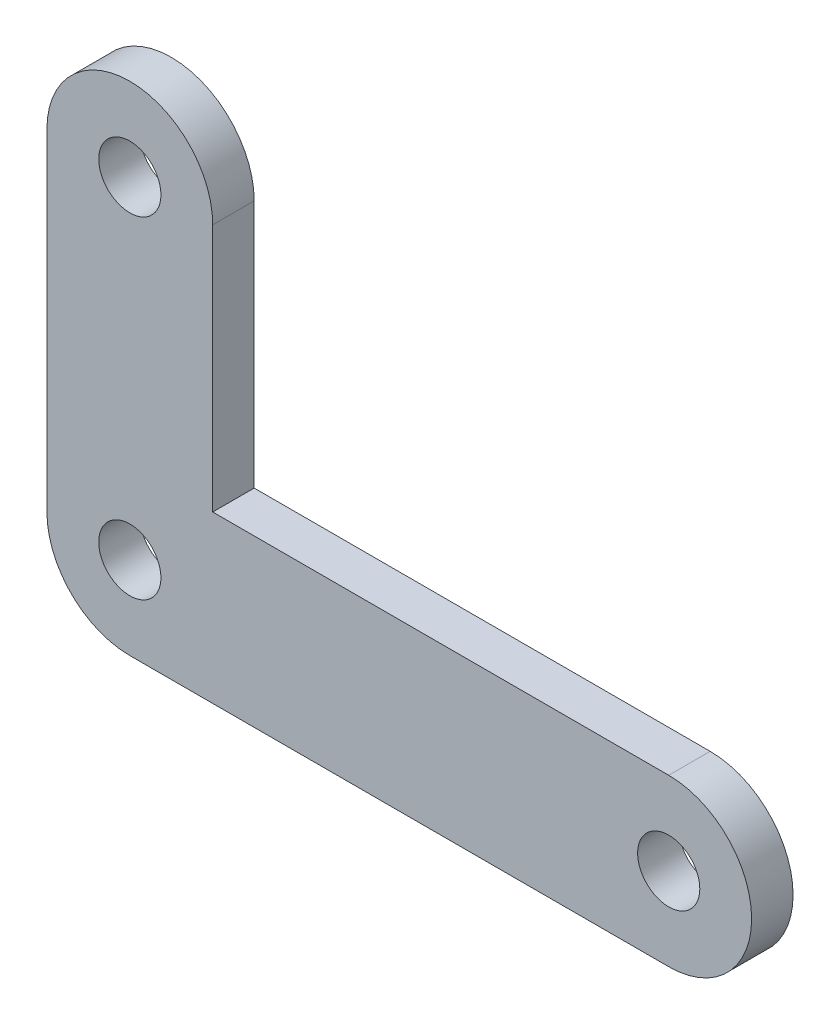
from build123d import *

# Parameters (mm, degrees)
SKETCH1_R           = 4.7625
BOSS_EXTRUDE1_DEPTH = 6.35


with BuildPart() as part:
    # Sketch1 → Boss-Extrude1 (new body)
    with BuildSketch(Plane.XY):
        with BuildLine():
            Line((-95.25, 50.8), (-95.25, 0))
            ThreePointArc((-95.25, 0), (-91.530256121, 8.980256121), (-82.55, 12.7))
            Line((-82.55, 12.7), (-69.85, 12.7))
            Line((-69.85, 12.7), (-69.85, 50.8))
            ThreePointArc((-69.85, 50.8), (-82.55, 63.5), (-95.25, 50.8))
        make_face()
        with Locations((-82.55, 50.8)):
            Circle(SKETCH1_R, mode=Mode.SUBTRACT)
        with BuildLine():
            ThreePointArc((-95.25, 0), (-91.530256121, -8.980256121), (-82.55, -12.7))
            ThreePointArc((-82.55, -12.7), (-73.569743879, -8.980256121), (-69.85, 0))
            Line((-69.85, 0), (-69.85, 12.7))
            Line((-69.85, 12.7), (-82.55, 12.7))
            ThreePointArc((-82.55, 12.7), (-91.530256121, 8.980256121), (-95.25, 0))
        make_face()
        with Locations((-82.55, 0)):
            Circle(SKETCH1_R, mode=Mode.SUBTRACT)
        with BuildLine():
            Line((-82.55, -12.7), (0, -12.7))
            ThreePointArc((0, -12.7), (12.7, 0), (0, 12.7))
            Line((0, 12.7), (-69.85, 12.7))
            Line((-69.85, 12.7), (-69.85, 0))
            ThreePointArc((-69.85, 0), (-73.569743879, -8.980256121), (-82.55, -12.7))
        make_face()
        Circle(SKETCH1_R, mode=Mode.SUBTRACT)
    extrude(amount=BOSS_EXTRUDE1_DEPTH)


solid = part.part
